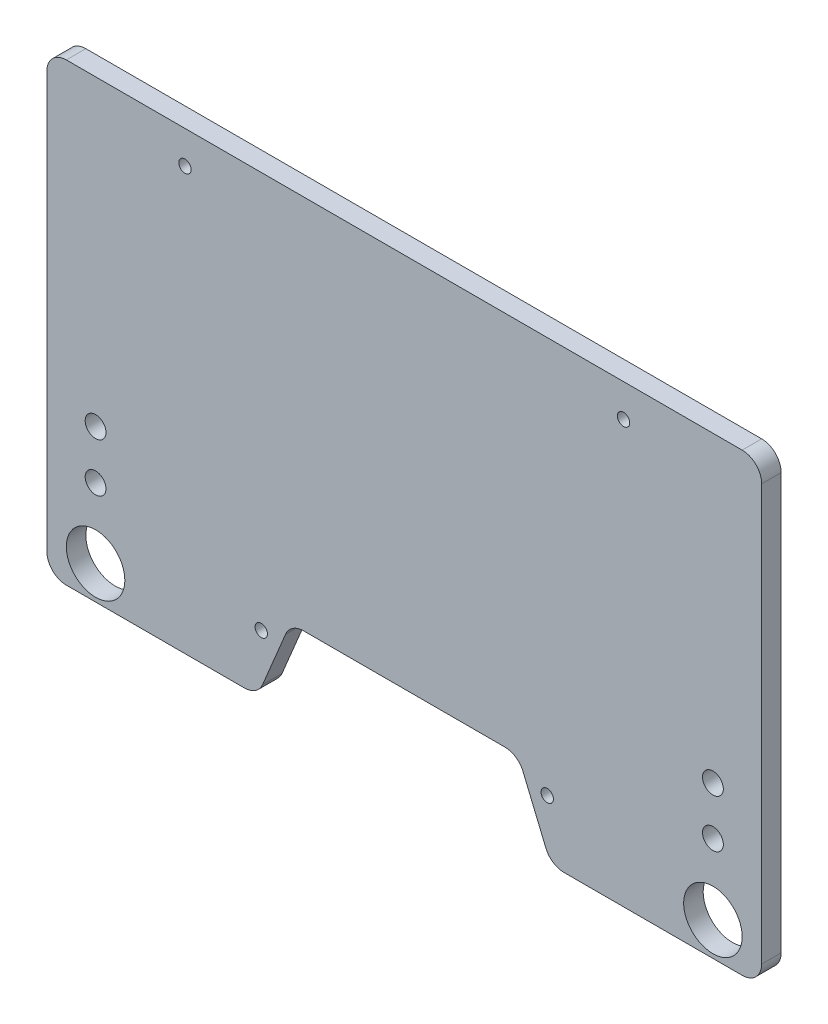
from build123d import *

# Parameters (mm, degrees)
SKETCH_1_R         = 1.6
SKETCH_1_R_2       = 0.95
EXTRUDE_1_DEPTH    = 3
SKETCH1_R          = 4.5
CUT_EXTRUDE1_DEPTH = 25


with BuildPart() as part:
    # 草图1 → 凸台-拉伸1 (new body)
    with BuildSketch(Plane.XY):
        with BuildLine():
            Line((32, 23.279914581), (63, 23.279914581))
            ThreePointArc((63, 23.279914581), (64.664100589, 22.776065464), (65.769230769, 21.433760735))
            Line((65.769230769, 21.433760735), (66.730769231, 19.126068427))
            Line((66.730769231, 19.126068427), (69.29930559, 12.961581165))
            ThreePointArc((69.29930559, 12.961581165), (70.404435771, 11.619276436), (72.068536359, 11.115427319))
            Line((72.068536359, 11.115427319), (99.5, 11.115427319))
            ThreePointArc((99.5, 11.115427319), (101.621320344, 11.994106975), (102.5, 14.115427319))
            Line((102.5, 14.115427319), (102.5, 78.115427319))
            ThreePointArc((102.5, 78.115427319), (101.621320344, 80.236747662), (99.5, 81.115427319))
            Line((99.5, 81.115427319), (-4.5, 81.115427319))
            ThreePointArc((-4.5, 81.115427319), (-6.621320344, 80.236747662), (-7.5, 78.115427319))
            Line((-7.5, 78.115427319), (-7.5, 14.115427319))
            ThreePointArc((-7.5, 14.115427319), (-6.621320344, 11.994106975), (-4.5, 11.115427319))
            Line((-4.5, 11.115427319), (22.931463641, 11.115427319))
            ThreePointArc((22.931463641, 11.115427319), (24.595564229, 11.619276436), (25.70069441, 12.961581165))
            Line((25.70069441, 12.961581165), (28.269230769, 19.126068427))
            Line((28.269230769, 19.126068427), (29.230769231, 21.433760735))
            ThreePointArc((29.230769231, 21.433760735), (30.335899411, 22.776065464), (32, 23.279914581))
        make_face()
        with Locations((0, 34.5)):
            Circle(SKETCH_1_R, mode=Mode.SUBTRACT)
        with Locations((0, 27)):
            Circle(SKETCH_1_R, mode=Mode.SUBTRACT)
        with Locations((95, 34.5)):
            Circle(SKETCH_1_R, mode=Mode.SUBTRACT)
        with Locations((95, 27.1)):
            Circle(SKETCH_1_R, mode=Mode.SUBTRACT)
        with Locations((13.75, 76.079914581)):
            Circle(SKETCH_1_R_2, mode=Mode.SUBTRACT)
        with Locations((81.25, 76.079914581)):
            Circle(SKETCH_1_R_2, mode=Mode.SUBTRACT)
        with Locations((69.5, 20.079914581)):
            Circle(SKETCH_1_R_2, mode=Mode.SUBTRACT)
        with Locations((25.5, 20.079914581)):
            Circle(SKETCH_1_R_2, mode=Mode.SUBTRACT)
    extrude(amount=EXTRUDE_1_DEPTH)

    # Sketch1 → Cut-Extrude1 (cut)
    with BuildSketch(Plane.XY.offset(3)):
        with Locations((0, 16.25)):
            Circle(SKETCH1_R)
        with Locations((95, 16.25)):
            Circle(SKETCH1_R)
    extrude(amount=-CUT_EXTRUDE1_DEPTH, mode=Mode.SUBTRACT)


solid = part.part
